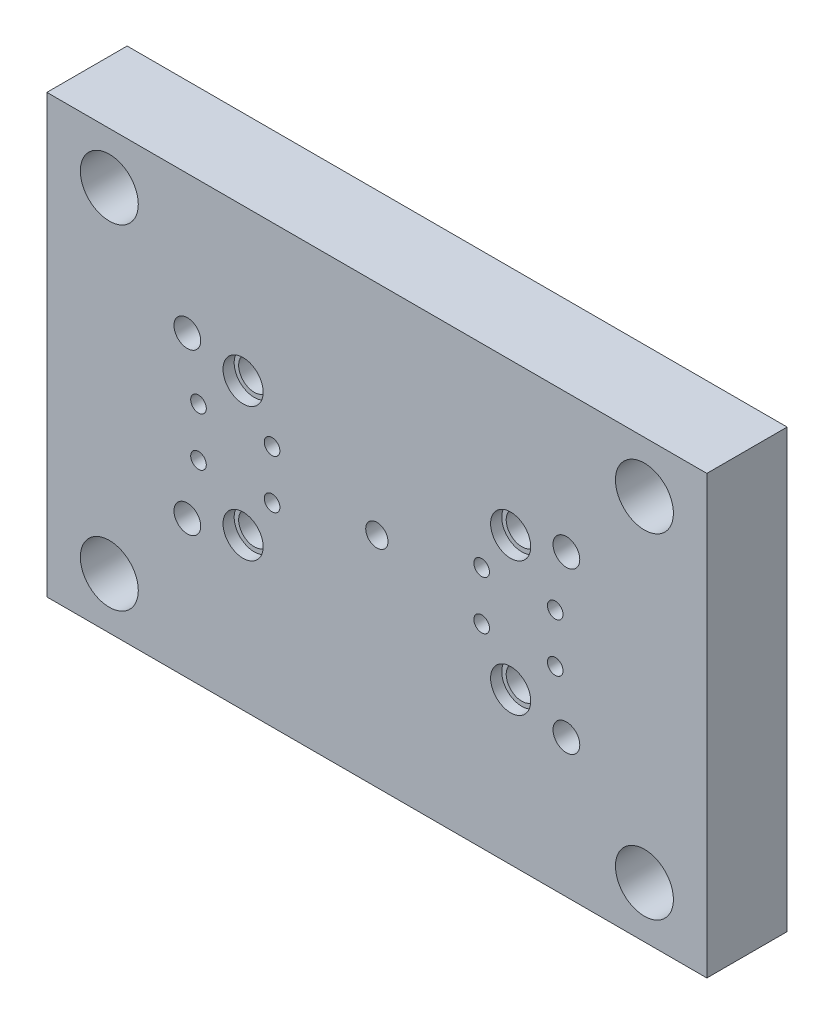
from build123d import *

# Parameters (mm, degrees)
SKETCH1_W                              = 296
SKETCH1_H                              = 196
SKETCH1_R                              = 13
SKETCH1_R_2                            = 3.5
SKETCH1_R_3                            = 6
SKETCH1_R_4                            = 5
EXTRUDE1_DEPTH                         = 36
CBORE_FOR_14_MM_CORE_PINS1_D           = 14
CBORE_FOR_14_MM_CORE_PINS1_CBORE_D     = 18
CBORE_FOR_14_MM_CORE_PINS1_CBORE_DEPTH = 5


with BuildPart() as part:
    # Sketch1 → Extrude1 (new body)
    with BuildSketch(Plane.XY):
        Rectangle(SKETCH1_W, SKETCH1_H)
        with Locations((-120, 75)):
            Circle(SKETCH1_R, mode=Mode.SUBTRACT)
        with Locations((-120, -75)):
            Circle(SKETCH1_R, mode=Mode.SUBTRACT)
        with Locations((120, 75)):
            Circle(SKETCH1_R, mode=Mode.SUBTRACT)
        with Locations((120, -75)):
            Circle(SKETCH1_R, mode=Mode.SUBTRACT)
        with Locations((-47, 10.939957651)):
            Circle(SKETCH1_R_2, mode=Mode.SUBTRACT)
        with Locations((-80, 10.939957651)):
            Circle(SKETCH1_R_2, mode=Mode.SUBTRACT)
        with Locations((-80, -10.939957651)):
            Circle(SKETCH1_R_2, mode=Mode.SUBTRACT)
        with Locations((-47, -10.939957651)):
            Circle(SKETCH1_R_2, mode=Mode.SUBTRACT)
        with Locations((47, -10.939957651)):
            Circle(SKETCH1_R_2, mode=Mode.SUBTRACT)
        with Locations((80, -10.939957651)):
            Circle(SKETCH1_R_2, mode=Mode.SUBTRACT)
        with Locations((80, 10.939957651)):
            Circle(SKETCH1_R_2, mode=Mode.SUBTRACT)
        with Locations((47, 10.939957651)):
            Circle(SKETCH1_R_2, mode=Mode.SUBTRACT)
        with Locations((-85, 36)):
            Circle(SKETCH1_R_3, mode=Mode.SUBTRACT)
        with Locations((-85, -36)):
            Circle(SKETCH1_R_3, mode=Mode.SUBTRACT)
        with Locations((85, 36)):
            Circle(SKETCH1_R_3, mode=Mode.SUBTRACT)
        with Locations((85, -36)):
            Circle(SKETCH1_R_3, mode=Mode.SUBTRACT)
        Circle(SKETCH1_R_4, mode=Mode.SUBTRACT)
    extrude(amount=-EXTRUDE1_DEPTH)

    # CBORE for 14 mm Core Pins1 (through all)
    with Locations(Plane.XY):
        with Locations((60, 30), (-60, 30), (-60, -30), (60, -30)):
            CounterBoreHole(CBORE_FOR_14_MM_CORE_PINS1_D / 2, CBORE_FOR_14_MM_CORE_PINS1_CBORE_D / 2, CBORE_FOR_14_MM_CORE_PINS1_CBORE_DEPTH)


solid = part.part
